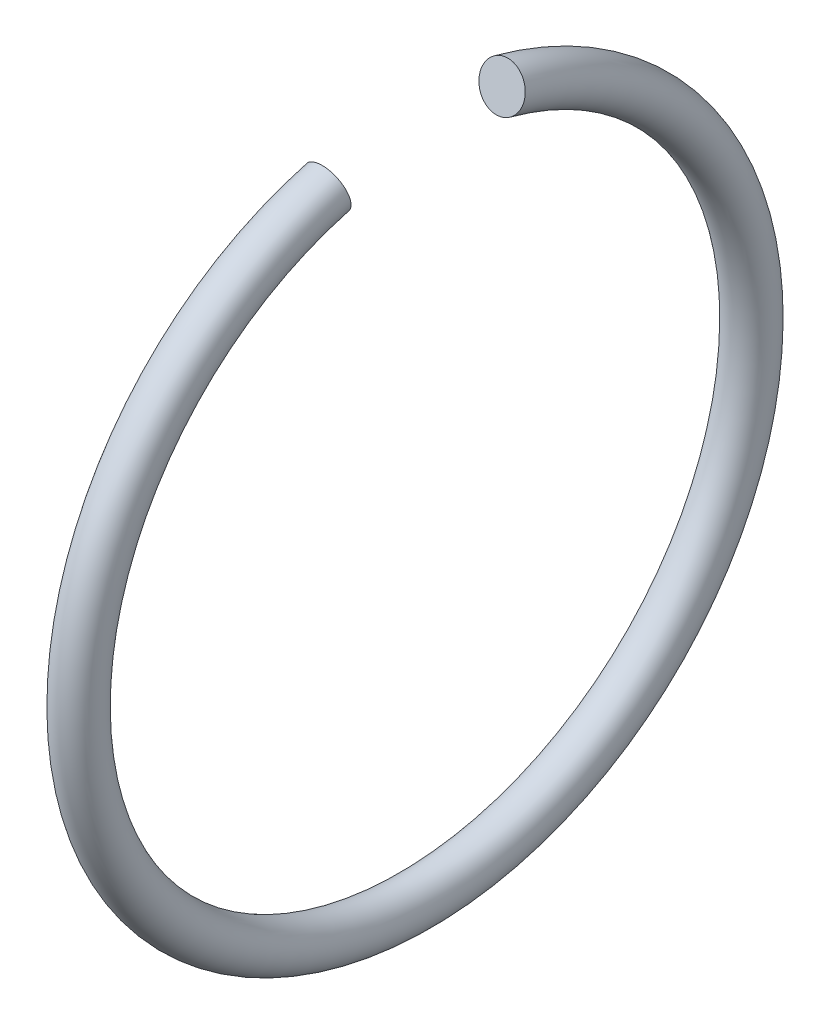
from build123d import *
from build123d.topology import SkipClean

# Parameters (mm, degrees)
SKICA1_R       = 1
ROTOVAT1_ANGLE = 330


with BuildPart() as part:
    # Skica1 → Rotovat1 (revolve, symmetric)
    with SkipClean():  # the faces are left unmerged after this step: merging them gives an invalid solid
        with BuildSketch(Plane.XY) as rotovat1_sk:
            with Locations((-325.05, -15)):
                Circle(SKICA1_R)
        revolve(axis=Axis((-67.482261058, 0, 0), (-1, 0, 0)), revolution_arc=ROTOVAT1_ANGLE / 2)
        revolve(rotovat1_sk.sketch, axis=Axis((-67.482261058, 0, 0), (1, 0, 0)), revolution_arc=ROTOVAT1_ANGLE / 2)


solid = part.part
